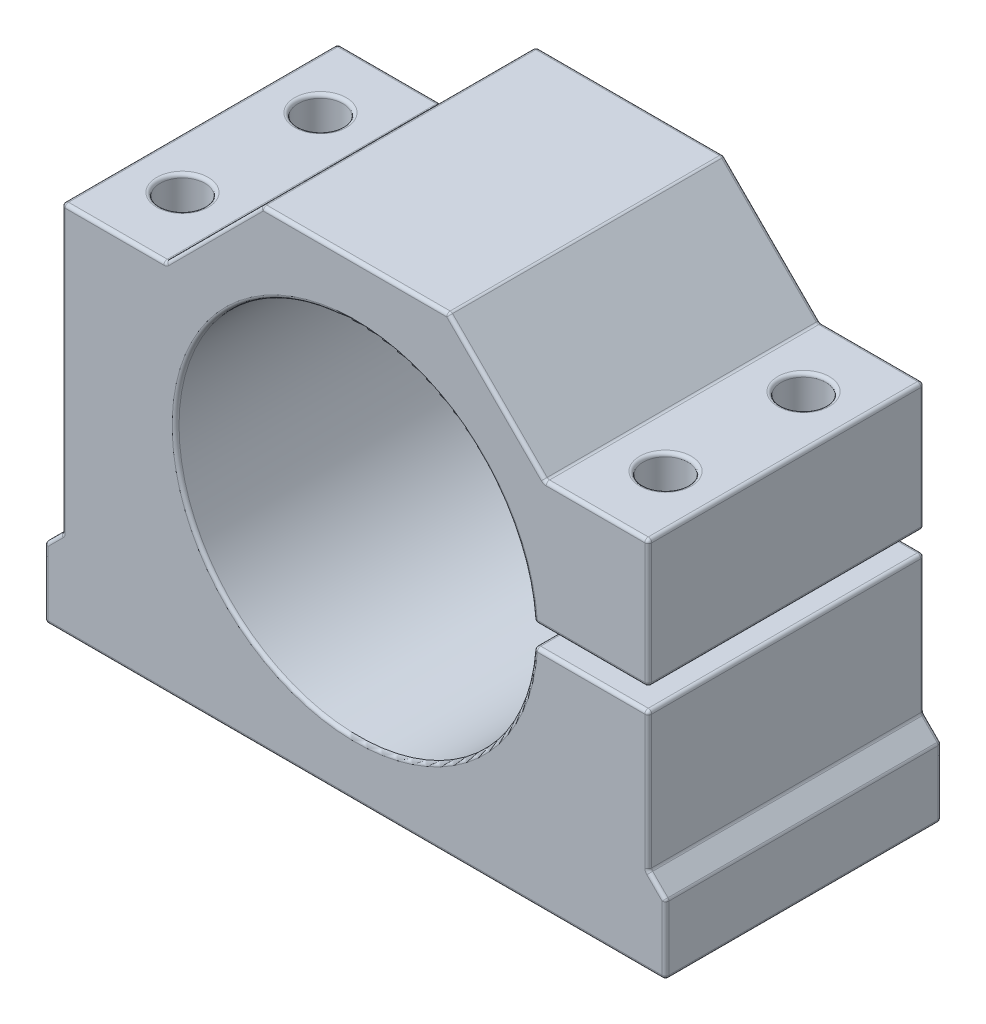
from build123d import *

# Parameters (mm, degrees)
BOSS_EXTRUDE1_DEPTH = 20
SKETCH2_R           = 3.25
CUT_EXTRUDE1_DEPTH  = 69
FILLET1_R           = 0.5


with BuildPart() as part:
    # Sketch1 → Boss-Extrude1 (new body, symmetric)
    with BuildSketch(Plane.XY):
        with BuildLine():
            Line((-45, -34), (45, -34))
            Line((45, -34), (45, -24))
            Line((45, -24), (42.5, -21.5))
            Line((42.5, -21.5), (42.5, -1.5))
            Line((42.5, -1.5), (25.956694705, -1.5))
            ThreePointArc((25.956694705, -1.5), (-26, 0), (25.956694705, 1.5))
            Line((25.956694705, 1.5), (42.5, 1.5))
            Line((42.5, 1.5), (42.5, 20))
            Line((42.5, 20), (27.5, 20))
            Line((27.5, 20), (13.5, 34))
            Line((13.5, 34), (-13.5, 34))
            Line((-13.5, 34), (-27.5, 20))
            Line((-27.5, 20), (-42.5, 20))
            Line((-42.5, 20), (-42.5, -21.5))
            Line((-42.5, -21.5), (-45, -24))
            Line((-45, -24), (-45, -34))
        make_face()
    extrude(amount=BOSS_EXTRUDE1_DEPTH, both=True)

    # Sketch2 → Cut-Extrude1 (cut, through all)
    with BuildSketch(Plane.XZ.offset(34)):
        with Locations((-35, 10)):
            Circle(SKETCH2_R)
        with Locations((-35, -10)):
            Circle(SKETCH2_R)
        with Locations((35, -10)):
            Circle(SKETCH2_R)
        with Locations((35, 10)):
            Circle(SKETCH2_R)
    extrude(amount=-CUT_EXTRUDE1_DEPTH, mode=Mode.SUBTRACT)

    # Fillet1
    fillet1_edges = [part.edges().sort_by_distance(p)[0] for p in [
        (34.228347352, 1.5, 20),
        (42.5, 10.75, 20),
        (34.228347352, -1.5, -20),
        (42.5, -11.5, -20),
        (43.75, -22.75, -20),
        (45, -29, -20),
        (0, -34, -20),
        (-45, -29, -20),
        (-43.75, -22.75, -20),
        (35, 20, 20),
        (-42.5, -0.75, -20),
        (-35, 20, -20),
        (-20.5, 27, -20),
        (0, 34, -20),
        (20.5, 27, -20),
        (35, 20, -20),
        (42.5, 10.75, -20),
        (34.228347352, 1.5, -20),
        (-26, 0, -20),
        (20.5, 27, 20),
        (25.956694705, -1.5, 0),
        (42.5, -1.5, 0),
        (42.5, -21.5, 0),
        (45, -24, 0),
        (45, -34, 0),
        (-45, -34, 0),
        (-45, -24, 0),
        (0, 34, 20),
        (-42.5, -21.5, 0),
        (-42.5, 20, 0),
        (-27.5, 20, 0),
        (-13.5, 34, 0),
        (13.5, 34, 0),
        (27.5, 20, 0),
        (42.5, 20, 0),
        (42.5, 1.5, 0),
        (25.956694705, 1.5, 0),
        (-20.5, 27, 20),
        (-35, 20, 20),
        (-42.5, -0.75, 20),
        (-43.75, -22.75, 20),
        (31.75, 1.5, 10),
        (31.75, 20, 10),
        (31.75, -1.5, 10),
        (-45, -29, 20),
        (31.75, 1.5, -10),
        (31.75, 20, -10),
        (31.75, -1.5, -10),
        (-26, 0, 20),
        (0, -34, 20),
        (-38.25, 20, -10),
        (-38.25, -34, -10),
        (-38.25, 20, 10),
        (45, -29, 20),
        (43.75, -22.75, 20),
        (42.5, -11.5, 20),
        (34.228347352, -1.5, 20),
    ]]
    fillet(fillet1_edges, radius=FILLET1_R)


solid = part.part
